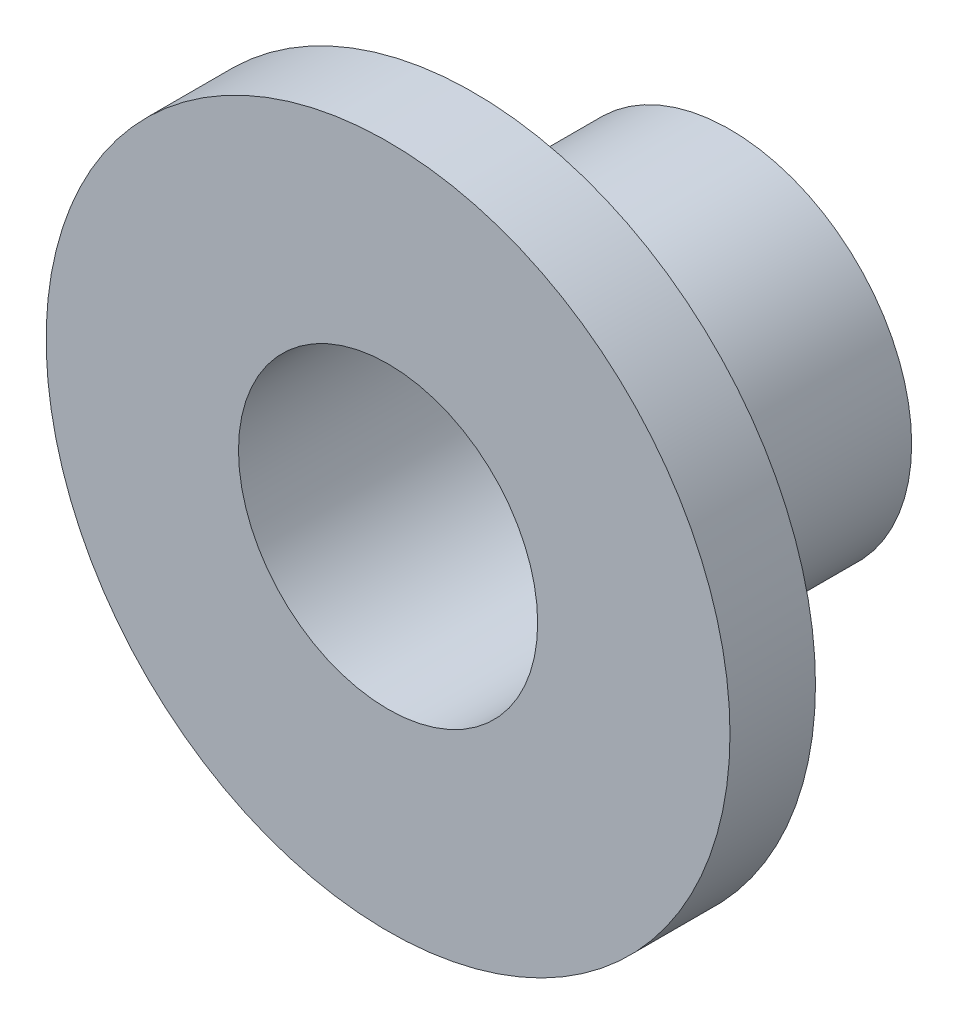
from build123d import *

# Parameters (mm, degrees)
SKETCH1_R           = 2.125
SKETCH1_R_2         = 1.75
BOSS_EXTRUDE1_DEPTH = 3
SKETCH2_R           = 4
SKETCH2_R_2         = 1.75
BOSS_EXTRUDE2_DEPTH = 1


with BuildPart() as part:
    # Sketch1 → Boss-Extrude1 (new body)
    with BuildSketch(Plane.XY):
        Circle(SKETCH1_R)
        Circle(SKETCH1_R_2, mode=Mode.SUBTRACT)
    extrude(amount=BOSS_EXTRUDE1_DEPTH)

    # Sketch2 → Boss-Extrude2 (add)
    with BuildSketch(Plane.XY.offset(3)):
        Circle(SKETCH2_R)
        Circle(SKETCH2_R_2, mode=Mode.SUBTRACT)
    extrude(amount=BOSS_EXTRUDE2_DEPTH)


solid = part.part
